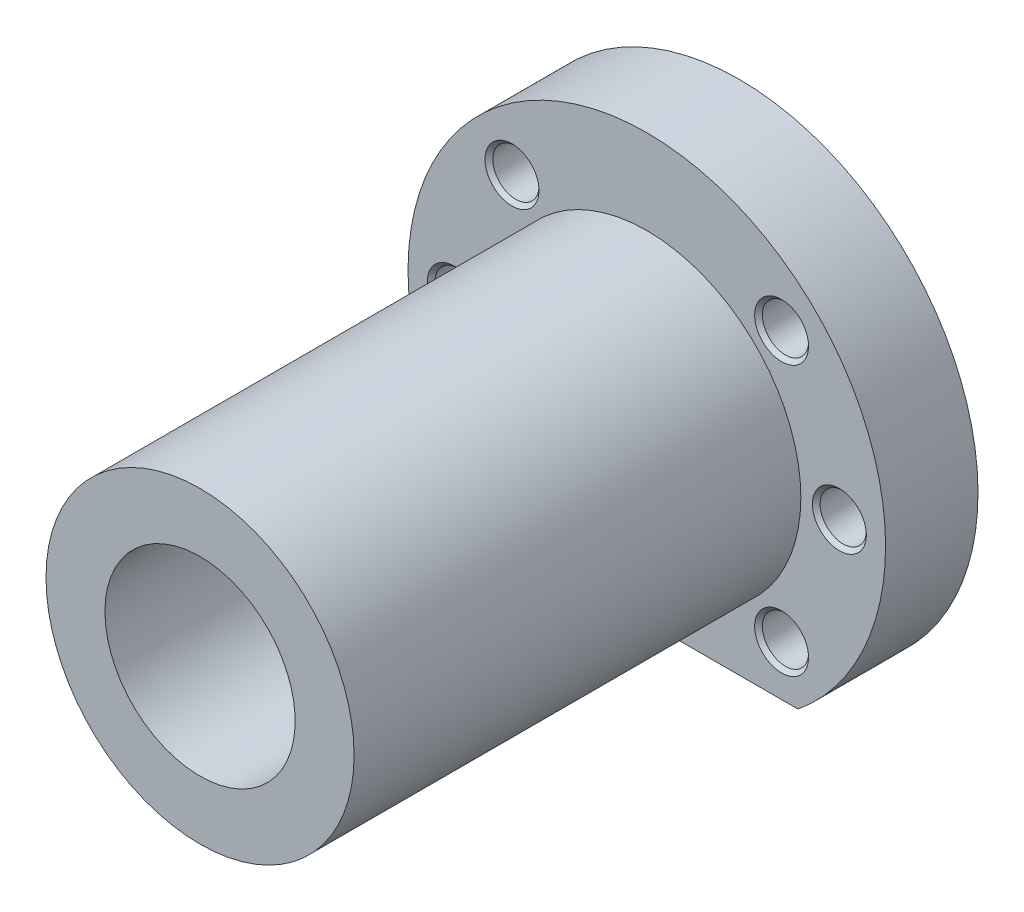
from build123d import *

# Parameters (mm, degrees)
SZKIC1_R                    = 20
DODANIE_WYCI_GNI_CIE1_DEPTH = 58
SZKIC3_R                    = 31
DODANIE_WYCI_GNI_CIE2_DEPTH = 12
SZKIC4_W                    = 39.24283374
SZKIC4_H                    = 7
WYTNIJ_WYCI_GNI_CIE1_DEPTH  = 12
SZKIC5_R                    = 12.35
WYTNIJ_WYCI_GNI_CIE2_DEPTH  = 70
SZKIC6_R                    = 3
WYTNIJ_WYCI_GNI_CIE3_DEPTH  = 12
SFAZOWANIE1_SIZE            = 0.5


with BuildPart() as part:
    # Szkic1 → Dodanie-wyciągnięcie1 (new body)
    with BuildSketch(Plane.XY):
        Circle(SZKIC1_R)
    extrude(amount=DODANIE_WYCI_GNI_CIE1_DEPTH)

    # Szkic3 → Dodanie-wyciągnięcie2 (add)
    with BuildSketch(Plane(origin=(0, 0, 0), x_dir=(-1, 0, 0), z_dir=(0, 0, -1))):
        Circle(SZKIC3_R)
    extrude(amount=DODANIE_WYCI_GNI_CIE2_DEPTH)

    # Szkic4 → Wytnij-wyciągnięcie1 (cut)
    with BuildSketch(Plane(origin=(0, 0, -12), x_dir=(-1, 0, 0), z_dir=(0, 0, -1))):
        with Locations((0, -27.5)):
            Rectangle(SZKIC4_W, SZKIC4_H)
    extrude(amount=-WYTNIJ_WYCI_GNI_CIE1_DEPTH, mode=Mode.SUBTRACT)

    # Szkic5 → Wytnij-wyciągnięcie2 (cut)
    with BuildSketch(Plane(origin=(0, 0, -12), x_dir=(-1, 0, 0), z_dir=(0, 0, -1))):
        Circle(SZKIC5_R)
    extrude(amount=-WYTNIJ_WYCI_GNI_CIE2_DEPTH, mode=Mode.SUBTRACT)

    # Szkic6 → Wytnij-wyciągnięcie3 (cut)
    with BuildSketch(Plane(origin=(0, 0, -12), x_dir=(-1, 0, 0), z_dir=(0, 0, -1))):
        with Locations((-17.5, 17.5)):
            Circle(SZKIC6_R)
        with Locations((-25, 0)):
            Circle(SZKIC6_R)
        with Locations((-17.5, -17.5)):
            Circle(SZKIC6_R)
        with Locations((17.5, -17.5)):
            Circle(SZKIC6_R)
        with Locations((25, 0)):
            Circle(SZKIC6_R)
        with Locations((17.5, 17.5)):
            Circle(SZKIC6_R)
    extrude(amount=-WYTNIJ_WYCI_GNI_CIE3_DEPTH, mode=Mode.SUBTRACT)

    # Sfazowanie1
    sfazowanie1_edges = [part.edges().sort_by_distance(p)[0] for p in [
        (-14.5, 17.5, 0),
        (-14.5, 17.5, -12),
        (-22, 0, 0),
        (-22, 0, -12),
        (-14.5, -17.5, 0),
        (-14.5, -17.5, -12),
        (28, 0, 0),
        (28, 0, -12),
        (20.5, -17.5, 0),
        (20.5, -17.5, -12),
        (20.5, 17.5, 0),
        (20.5, 17.5, -12),
    ]]
    chamfer(sfazowanie1_edges, length=SFAZOWANIE1_SIZE)


solid = part.part
